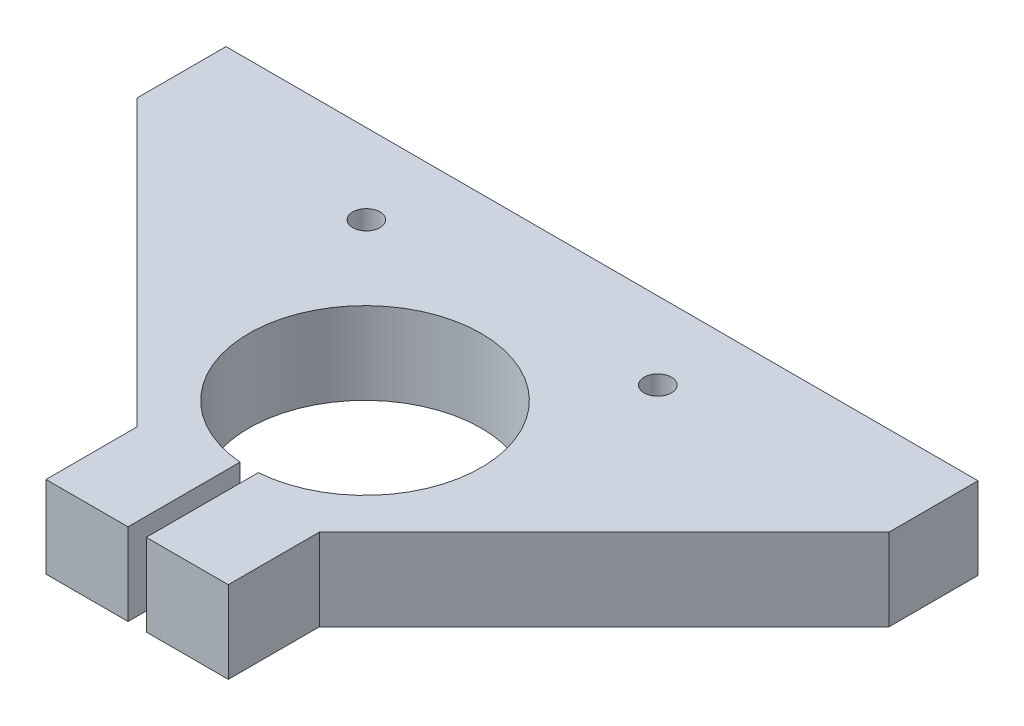
from build123d import *

# Parameters (mm, degrees)
EXTRUDE1_DEPTH           = 18
F_6_0_6_DIAMETER_HOLE1_D = 6


with BuildPart() as part:
    # Sketch1 → Extrude1 (new body)
    with BuildSketch(Plane(origin=(0, 0, 0), x_dir=(1, 0, 0), z_dir=(0, 1, 0))):
        with BuildLine():
            Line((-83.124824855, -7.773679355), (-20.624824855, -70.273679355))
            Line((-20.624824855, -70.273679355), (-20.624824855, -90.273679355))
            Line((-20.624824855, -90.273679355), (-2.624824855, -90.273679355))
            Line((-2.624824855, -90.273679355), (-2.624824855, -65.695126993))
            ThreePointArc((-2.624824855, -65.695126993), (-0.624824855, -14.773679355), (1.375175145, -65.695126993))
            Line((1.375175145, -65.695126993), (1.375175145, -90.273679355))
            Line((1.375175145, -90.273679355), (19.375175145, -90.273679355))
            Line((19.375175145, -90.273679355), (19.375175145, -70.273679355))
            Line((19.375175145, -70.273679355), (81.875175145, -7.773679355))
            Line((81.875175145, -7.773679355), (81.875175145, 11.726320645))
            Line((81.875175145, 11.726320645), (-83.124824855, 11.726320645))
            Line((-83.124824855, 11.726320645), (-83.124824855, -7.773679355))
        make_face()
    extrude(amount=EXTRUDE1_DEPTH)

    # Ø6.0 (6) Diameter Hole1 (through all)
    with Locations(Plane(origin=(-34.816928484, 18, 5.785627569), x_dir=(0, 0, 1), z_dir=(0, 1, 0))):
        with Locations((0, 0), (-0.569202013, 63.371157488)):
            Hole(F_6_0_6_DIAMETER_HOLE1_D / 2)


solid = part.part
